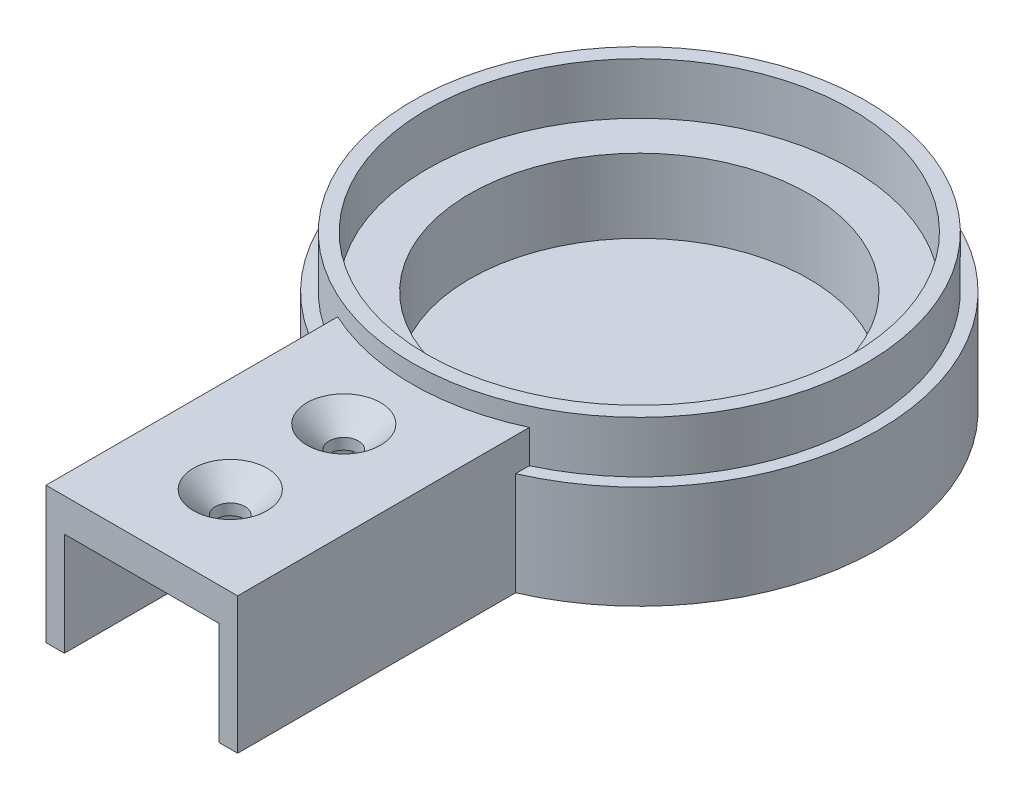
from build123d import *

# Parameters (mm, degrees)
ESQUISSE1_R                    = 32.5
BOSS_EXTRU_1_DEPTH             = 4
ESQUISSE2_R                    = 32.5
ESQUISSE2_R_2                  = 23
BOSS_EXTRU_2_DEPTH             = 10
ESQUISSE4_R                    = 30.8
ESQUISSE4_R_2                  = 28.8
BOSS_EXTRU_4_DEPTH             = 7
BOSS_EXTRU_5_DEPTH             = 35
BOSS_EXTRU_5_DIRECTION_2_REACH = 67
ESQUISSE6_R                    = 2
ENL_V_MAT_EXTRU_1_DEPTH        = 5
CHANFREIN1_SIZE                = 3
ENL_V_MAT_EXTRU_2_REACH        = 67
ESQUISSE8_W                    = 4
ESQUISSE8_H                    = 8


with BuildPart() as part:
    # Esquisse1 → Boss.-Extru.1 (new body)
    with BuildSketch(Plane(origin=(0, 0, 0), x_dir=(1, 0, 0), z_dir=(0, 1, 0))):
        Circle(ESQUISSE1_R)
    extrude(amount=BOSS_EXTRU_1_DEPTH)

    # Esquisse2 → Boss.-Extru.2 (add)
    with BuildSketch(Plane(origin=(0, 4, 0), x_dir=(1, 0, 0), z_dir=(0, 1, 0))):
        Circle(ESQUISSE2_R)
        Circle(ESQUISSE2_R_2, mode=Mode.SUBTRACT)
    extrude(amount=BOSS_EXTRU_2_DEPTH)

    # Esquisse4 → Boss.-Extru.4 (add)
    with BuildSketch(Plane(origin=(0, 14, 0), x_dir=(1, 0, 0), z_dir=(0, 1, 0))):
        Circle(ESQUISSE4_R)
        Circle(ESQUISSE4_R_2, mode=Mode.SUBTRACT)
    extrude(amount=BOSS_EXTRU_4_DEPTH)

    # Esquisse5 → Boss.-Extru.5 (add)
    with BuildSketch(Plane.XY.offset(32.5)):
        Polygon((13, 18.5), (-13, 18.5), (-13, 0), (-10.5, 0), (-10.5, 14), (10.5, 14), (10.5, 0), (13, 0), align=None)
    extrude(amount=BOSS_EXTRU_5_DEPTH)

    # Esquisse5 → Boss.-Extru.5 direction 2 (add, up to next)
    with BuildSketch(Plane.XY.offset(32.5), mode=Mode.PRIVATE) as boss_extru_5_direction_2_sk1:
        Polygon((13, 18.5), (-13, 18.5), (-13, 0), (-10.5, 0), (-10.5, 14), (10.5, 14), (10.5, 0), (13, 0), align=None)
    boss_extru_5_direction_2_tool1 = extrude(boss_extru_5_direction_2_sk1.sketch, amount=-BOSS_EXTRU_5_DIRECTION_2_REACH, mode=Mode.PRIVATE) - part.part
    add(boss_extru_5_direction_2_tool1.solids().sort_by_distance((0, 18.1809, 32.5))[0])

    # Esquisse6 → Enlèv. mat.-Extru.1 (cut)
    with BuildSketch(Plane(origin=(0, 18.5, 0), x_dir=(1, 0, 0), z_dir=(0, 1, 0))):
        with Locations((0, -55.5)):
            Circle(ESQUISSE6_R)
        with Locations((0, -40.1)):
            Circle(ESQUISSE6_R)
    extrude(amount=-ENL_V_MAT_EXTRU_1_DEPTH, mode=Mode.SUBTRACT)

    # Chanfrein1
    chanfrein1_edges = [part.edges().sort_by_distance(p)[0] for p in [
        (-2, 18.5, 55.5),
        (-2, 18.5, 40.1),
    ]]
    chamfer(chanfrein1_edges, length=CHANFREIN1_SIZE)

    # Esquisse8 → Enlèv. mat.-Extru.2 (cut, up to next)
    with BuildSketch(Plane.XY.offset(32.5), mode=Mode.PRIVATE) as enl_v_mat_extru_2_sk1:
        with Locations((-8.5, 8)):
            Rectangle(ESQUISSE8_W, ESQUISSE8_H)
    enl_v_mat_extru_2_tool1 = extrude(enl_v_mat_extru_2_sk1.sketch, amount=-ENL_V_MAT_EXTRU_2_REACH, mode=Mode.PRIVATE) & part.part
    add(enl_v_mat_extru_2_tool1.solids().sort_by_distance((-8.5, 8, 32.5))[0], mode=Mode.SUBTRACT)
    # Esquisse8 → Enlèv. mat.-Extru.2 (cut, up to next)
    with BuildSketch(Plane.XY.offset(32.5), mode=Mode.PRIVATE) as enl_v_mat_extru_2_sk2:
        with Locations((8.5, 8)):
            Rectangle(ESQUISSE8_W, ESQUISSE8_H)
    enl_v_mat_extru_2_tool2 = extrude(enl_v_mat_extru_2_sk2.sketch, amount=-ENL_V_MAT_EXTRU_2_REACH, mode=Mode.PRIVATE) & part.part
    add(enl_v_mat_extru_2_tool2.solids().sort_by_distance((8.5, 8, 32.5))[0], mode=Mode.SUBTRACT)


solid = part.part
